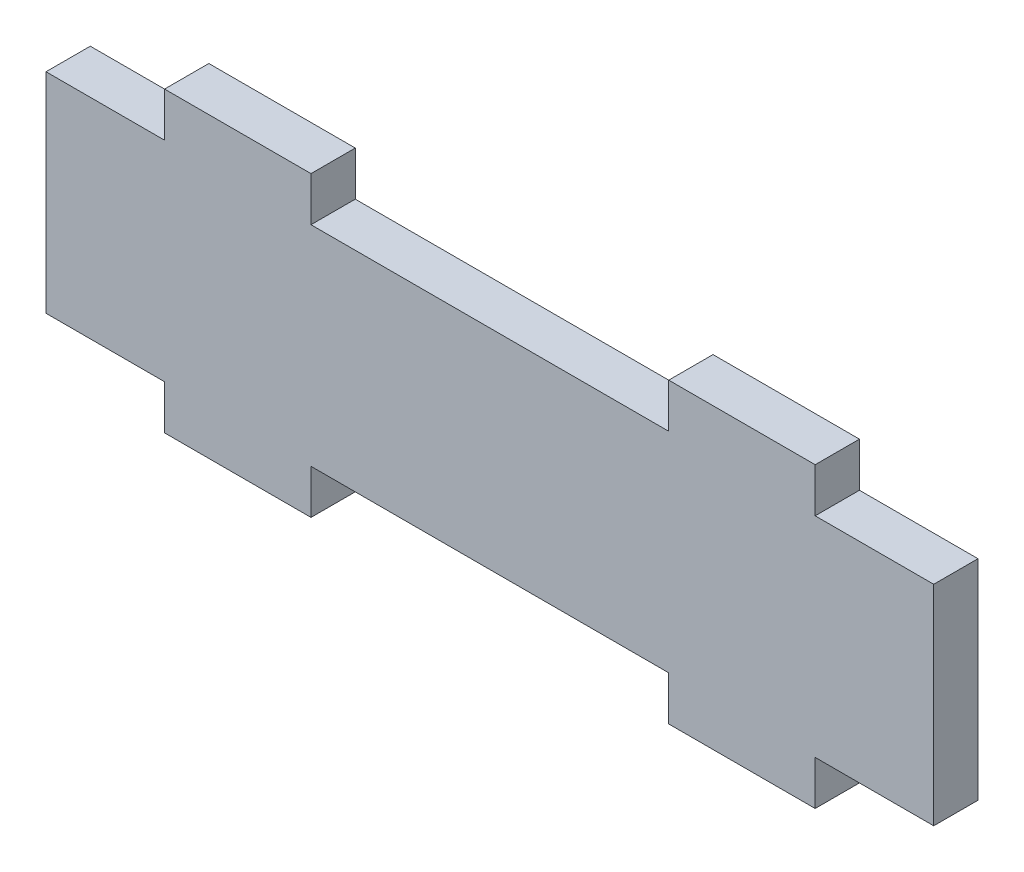
from build123d import *

# Parameters (mm, degrees)
BOSS_EXTRUDE1_DEPTH = 3.175


with BuildPart() as part:
    # Sketch1 → Boss-Extrude1 (new body)
    with BuildSketch(Plane.XY):
        Polygon((-31.825, 7.5), (-31.825, -7.5), (-23.325, -7.5), (-23.325, -10.675), (-12.825, -10.675), (-12.825, -7.5), (12.825, -7.5), (12.825, -10.675), (23.325, -10.675), (23.325, -7.5), (31.825, -7.5), (31.825, 7.5), (23.325, 7.5), (23.325, 10.675), (12.825, 10.675), (12.825, 7.5), (-12.825, 7.5), (-12.825, 10.675), (-23.325, 10.675), (-23.325, 7.5), align=None)
    extrude(amount=BOSS_EXTRUDE1_DEPTH)


solid = part.part
